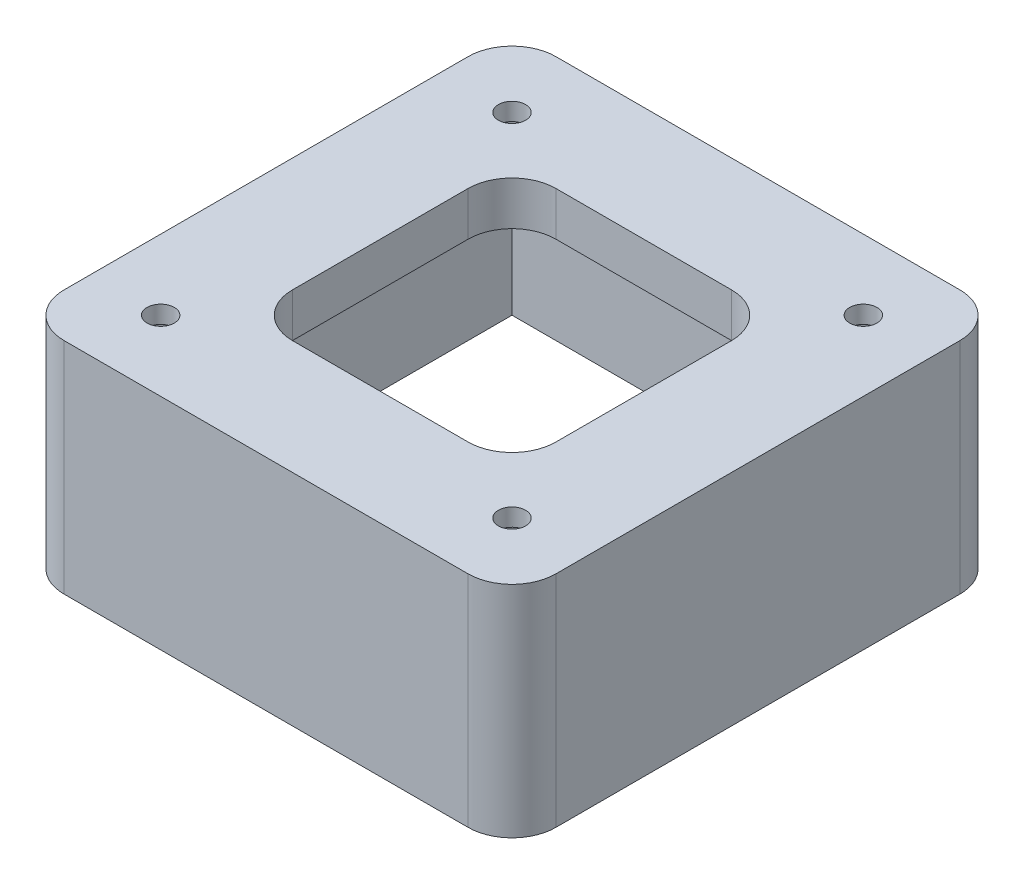
from build123d import *

# Parameters (mm, degrees)
SKETCH1_W           = 56
SKETCH1_H           = 56
SKETCH1_R           = 1.55
SKETCH1_W_2         = 30
SKETCH1_H_2         = 30
BOSS_EXTRUDE1_DEPTH = 5
SKETCH2_R           = 3.55
CUT_EXTRUDE1_DEPTH  = 3
FILLET1_R           = 5
SKETCH3_W           = 56
SKETCH3_H           = 56
SKETCH3_W_2         = 50
SKETCH3_H_2         = 50
BOSS_EXTRUDE2_DEPTH = 20
FILLET2_R           = 5


with BuildPart() as part:
    # Sketch1 → Boss-Extrude1 (new body)
    with BuildSketch(Plane(origin=(0, 0, 0), x_dir=(1, 0, 0), z_dir=(0, 1, 0))):
        Rectangle(SKETCH1_W, SKETCH1_H)
        with Locations((-20, 20)):
            Circle(SKETCH1_R, mode=Mode.SUBTRACT)
        with Locations((20, 20)):
            Circle(SKETCH1_R, mode=Mode.SUBTRACT)
        with Locations((20, -20)):
            Circle(SKETCH1_R, mode=Mode.SUBTRACT)
        with Locations((-20, -20)):
            Circle(SKETCH1_R, mode=Mode.SUBTRACT)
        Rectangle(SKETCH1_W_2, SKETCH1_H_2, mode=Mode.SUBTRACT)
    extrude(amount=BOSS_EXTRUDE1_DEPTH)

    # Sketch2 → Cut-Extrude1 (cut)
    with BuildSketch(Plane.XZ):
        with Locations((-20, 20)):
            Circle(SKETCH2_R)
        with Locations((20, 20)):
            Circle(SKETCH2_R)
        with Locations((-20, -20)):
            Circle(SKETCH2_R)
        with Locations((20, -20)):
            Circle(SKETCH2_R)
    extrude(amount=-CUT_EXTRUDE1_DEPTH, mode=Mode.SUBTRACT)

    # Fillet1
    fillet1_edges = [part.edges().sort_by_distance(p)[0] for p in [
        (15, 2.5, 15),
        (15, 2.5, -15),
        (-15, 2.5, -15),
        (-15, 2.5, 15),
    ]]
    fillet(fillet1_edges, radius=FILLET1_R)

    # Sketch3 → Boss-Extrude2 (add)
    with BuildSketch(Plane.XZ):
        Rectangle(SKETCH3_W, SKETCH3_H)
        Rectangle(SKETCH3_W_2, SKETCH3_H_2, mode=Mode.SUBTRACT)
    extrude(amount=BOSS_EXTRUDE2_DEPTH)

    # Fillet2
    fillet2_edges = [part.edges().sort_by_distance(p)[0] for p in [
        (-28, -7.5, -28),
        (28, -7.5, -28),
        (28, -7.5, 28),
        (-28, -7.5, 28),
    ]]
    fillet(fillet2_edges, radius=FILLET2_R)


solid = part.part
